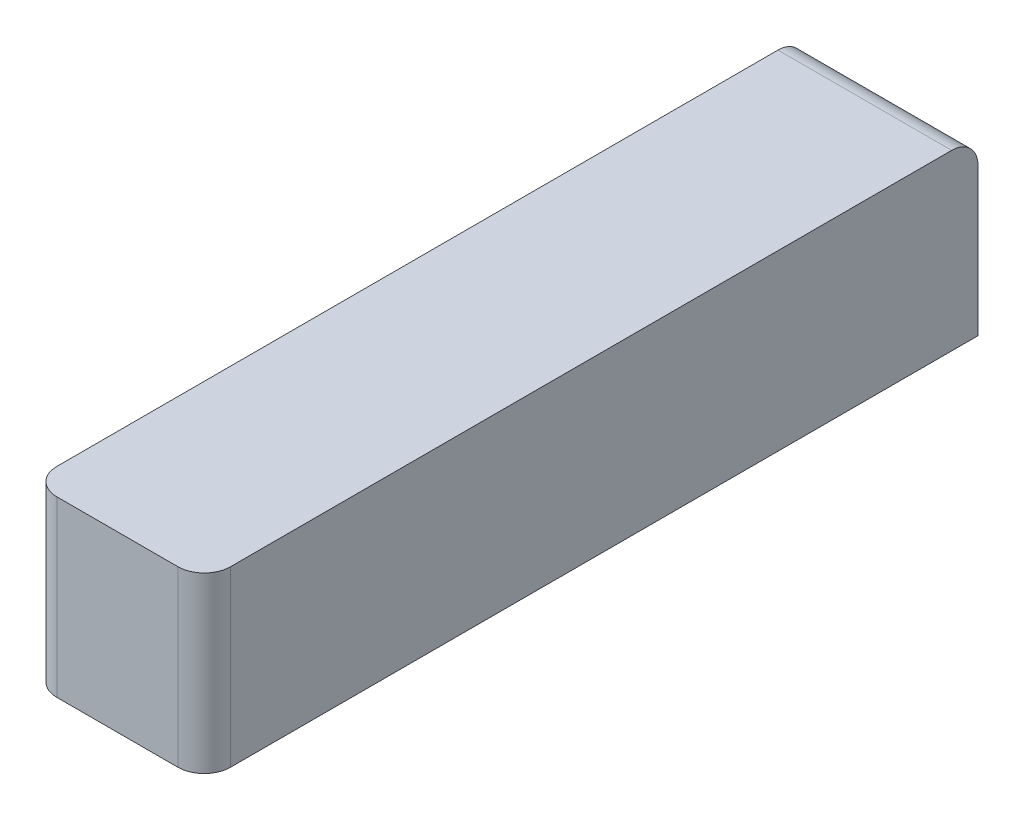
from build123d import *

# Parameters (mm, degrees)
SKETCH1_W           = 33
SKETCH1_H           = 147
BOSS_EXTRUDE1_DEPTH = 33
FILLET1_R           = 5


with BuildPart() as part:
    # Sketch1 → Boss-Extrude1 (new body)
    with BuildSketch(Plane(origin=(0, 0, 0), x_dir=(1, 0, 0), z_dir=(0, 1, 0))):
        Rectangle(SKETCH1_W, SKETCH1_H)
    extrude(amount=BOSS_EXTRUDE1_DEPTH)

    # Fillet1
    fillet1_edges = [part.edges().sort_by_distance(p)[0] for p in [
        (0, 33, -73.5),
        (16.5, 16.5, 73.5),
        (-16.5, 16.5, 73.5),
    ]]
    fillet(fillet1_edges, radius=FILLET1_R)


solid = part.part
